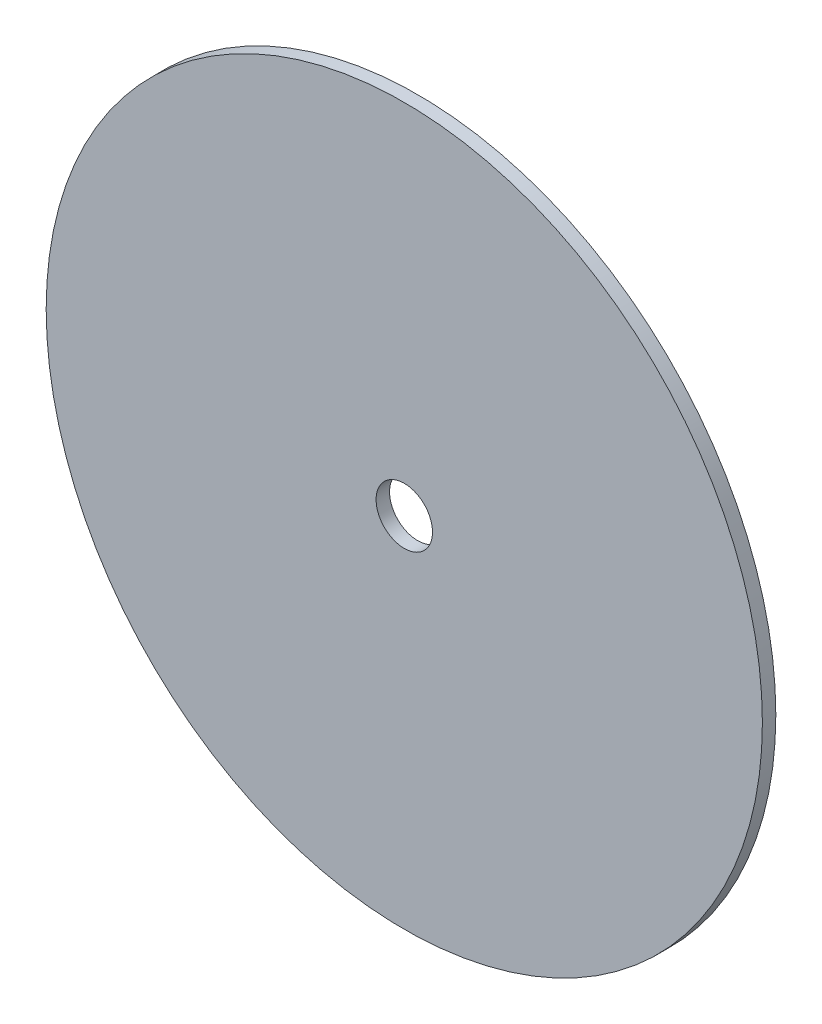
from build123d import *

# Parameters (mm, degrees)
ESQUISSE1_R        = 160
ESQUISSE1_R_2      = 12.6
BOSS_EXTRU_1_DEPTH = 6


with BuildPart() as part:
    # Esquisse1 → Boss.-Extru.1 (new body)
    with BuildSketch(Plane.XY):
        Circle(ESQUISSE1_R)
        Circle(ESQUISSE1_R_2, mode=Mode.SUBTRACT)
    extrude(amount=BOSS_EXTRU_1_DEPTH)


solid = part.part
